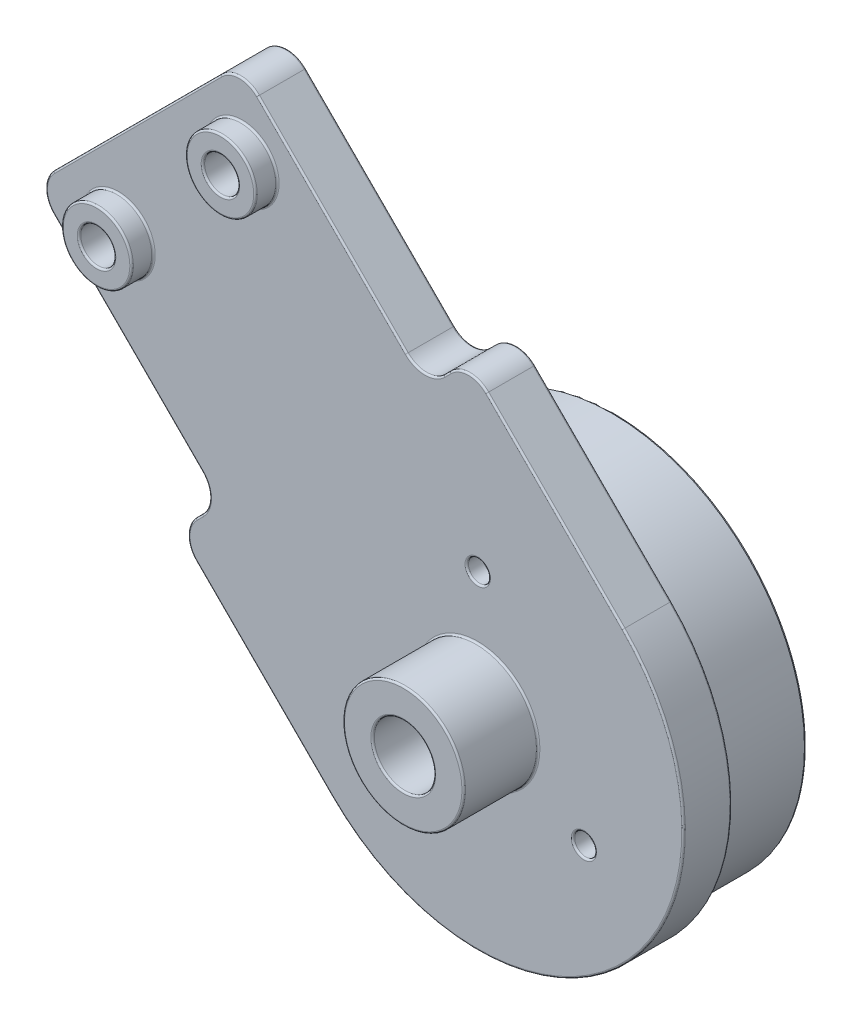
from build123d import *

# Parameters (mm, degrees)
SKETCH6_R           = 10
SKETCH6_R_2         = 1
BOSS_EXTRUDE1_DEPTH = 2.75
SKETCH7_R           = 10
BOSS_EXTRUDE2_DEPTH = 1
SKETCH8_R           = 11
SKETCH8_R_2         = 10
BOSS_EXTRUDE3_DEPTH = 5
FILLET1_R           = 1.5
SKETCH9_R           = 2
SKETCH9_R_2         = 1
BOSS_EXTRUDE4_DEPTH = 1.25
SKETCH12_R          = 1.75
CUT_EXTRUDE1_DEPTH  = 1
SKETCH13_R          = 3.45
SKETCH13_R_2        = 1.75
BOSS_EXTRUDE6_DEPTH = 4.25
SKETCH14_R          = 0.625
CUT_EXTRUDE2_DEPTH  = 1
FILLET3_R           = 0.1


with BuildPart() as part:
    # Sketch6 → Boss-Extrude1 (new body)
    with BuildSketch(Plane.XY):
        with BuildLine():
            Line((74.720932573, 13.611805538), (86.388194462, 25.279067427))
            Line((86.388194462, 25.279067427), (96.99479618, 14.67246571))
            Line((96.99479618, 14.67246571), (99.469669914, 17.147339444))
            Line((99.469669914, 17.147339444), (108.308504679, 8.308504679))
            ThreePointArc((108.308504679, 8.308504679), (108.308504679, -8.308504679), (91.691495321, -8.308504679))
            Line((91.691495321, -8.308504679), (82.852660556, 0.530330086))
            Line((82.852660556, 0.530330086), (85.32753429, 3.00520382))
            Line((85.32753429, 3.00520382), (74.720932573, 13.611805538))
        make_face()
        with Locations((100, 0)):
            Circle(SKETCH6_R, mode=Mode.SUBTRACT)
        with Locations((86.564971157, 20.506096654)):
            Circle(SKETCH6_R_2, mode=Mode.SUBTRACT)
        with Locations((79.493903346, 13.435028843)):
            Circle(SKETCH6_R_2, mode=Mode.SUBTRACT)
    extrude(amount=BOSS_EXTRUDE1_DEPTH)

    # Sketch7 → Boss-Extrude2 (add)
    with BuildSketch(Plane.XY.offset(2.75)):
        with Locations((100, 0)):
            Circle(SKETCH7_R)
    extrude(amount=-BOSS_EXTRUDE2_DEPTH)

    # Sketch8 → Boss-Extrude3 (add)
    with BuildSketch(Plane(origin=(0, 0, 0), x_dir=(-1, 0, 0), z_dir=(0, 0, -1))):
        with Locations((-100, 0)):
            Circle(SKETCH8_R)
        with Locations((-100, 0)):
            Circle(SKETCH8_R_2, mode=Mode.SUBTRACT)
    extrude(amount=BOSS_EXTRUDE3_DEPTH)

    # Fillet1
    fillet1_edges = [part.edges().sort_by_distance(p)[0] for p in [
        (74.720932573, 13.611805538, 1.375),
        (86.388194462, 25.279067427, 1.375),
        (96.99479618, 14.67246571, 1.375),
        (99.469669914, 17.147339444, 1.375),
        (82.852660556, 0.530330086, 1.375),
        (85.32753429, 3.00520382, 1.375),
    ]]
    fillet(fillet1_edges, radius=FILLET1_R)

    # Sketch9 → Boss-Extrude4 (add)
    with BuildSketch(Plane.XY.offset(2.75)):
        with Locations((79.493903346, 13.435028843)):
            Circle(SKETCH9_R)
        with Locations((79.493903346, 13.435028843)):
            Circle(SKETCH9_R_2, mode=Mode.SUBTRACT)
        with Locations((86.564971157, 20.506096654)):
            Circle(SKETCH9_R)
        with Locations((86.564971157, 20.506096654)):
            Circle(SKETCH9_R_2, mode=Mode.SUBTRACT)
    extrude(amount=BOSS_EXTRUDE4_DEPTH)

    # Sketch12 → Cut-Extrude1 (cut)
    with BuildSketch(Plane.XY.offset(2.75)):
        with Locations((100, 0)):
            Circle(SKETCH12_R)
    extrude(amount=-CUT_EXTRUDE1_DEPTH, mode=Mode.SUBTRACT)

    # Sketch13 → Boss-Extrude6 (add)
    with BuildSketch(Plane.XY.offset(2.75)):
        with Locations((100, 0)):
            Circle(SKETCH13_R)
        with Locations((100, 0)):
            Circle(SKETCH13_R_2, mode=Mode.SUBTRACT)
    extrude(amount=BOSS_EXTRUDE6_DEPTH)

    # Sketch14 → Cut-Extrude2 (cut)
    with BuildSketch(Plane.XY.offset(2.75)):
        with Locations((100, 7)):
            Circle(SKETCH14_R)
        with Locations((106.062177826, -3.5)):
            Circle(SKETCH14_R)
        with Locations((93.937822174, -3.5)):
            Circle(SKETCH14_R)
    extrude(amount=-CUT_EXTRUDE2_DEPTH, mode=Mode.SUBTRACT)

    # Fillet3
    fillet3_edges = [part.edges().sort_by_distance(p)[0] for p in [
        (108.308504679, -8.308504679, 0),
        (98.25, 0, 1.75),
        (96.55, 0, 7),
        (96.55, 0, 2.75),
        (98.25, 0, 7),
        (99.375, 7, 2.75),
        (99.375, 7, 1.75),
        (105.437177826, -3.5, 2.75),
        (105.437177826, -3.5, 1.75),
        (93.312822174, -3.5, 2.75),
        (93.312822174, -3.5, 1.75),
        (108.308504679, -8.308504679, 2.75),
        (104.419417382, 12.197591975, 2.75),
        (85.564971157, 20.506096654, 0),
        (78.493903346, 13.435028843, 0),
        (90, 0, 1.75),
        (111, 0, 0),
        (111, 0, -5),
        (110, 0, -5),
        (80.024233431, 8.308504679, 0),
        (80.024233431, 8.308504679, 2.75),
        (80.554563517, 19.445436483, 0),
        (91.691495321, 19.975766569, 0),
        (98.232233047, 15.909902577, 0),
        (87.802408025, -4.419417382, 0),
        (84.090097423, 1.767766953, 0),
        (86.388194462, 24.657747084, 0),
        (83.4739809, 0.530330086, 0),
        (99.469669914, 16.5260191, 0),
        (75.342252916, 13.611805538, 0),
        (80.554563517, 19.445436483, 2.75),
        (84.090097423, 1.767766953, 2.75),
        (87.802408025, -4.419417382, 2.75),
        (98.232233047, 15.909902577, 2.75),
        (91.691495321, 19.975766569, 2.75),
        (86.388194462, 24.657747084, 2.75),
        (83.4739809, 0.530330086, 2.75),
        (99.469669914, 16.5260191, 2.75),
        (75.342252916, 13.611805538, 2.75),
        (96.99479618, 15.293786053, 0),
        (96.99479618, 15.293786053, 2.75),
        (84.706213947, 3.00520382, 0),
        (84.706213947, 3.00520382, 2.75),
        (77.493903346, 13.435028843, 4),
        (77.493903346, 13.435028843, 2.75),
        (78.493903346, 13.435028843, 4),
        (84.564971157, 20.506096654, 4),
        (104.419417382, 12.197591975, 0),
        (84.564971157, 20.506096654, 2.75),
        (85.564971157, 20.506096654, 4),
    ]]
    fillet(fillet3_edges, radius=FILLET3_R)


solid = part.part
